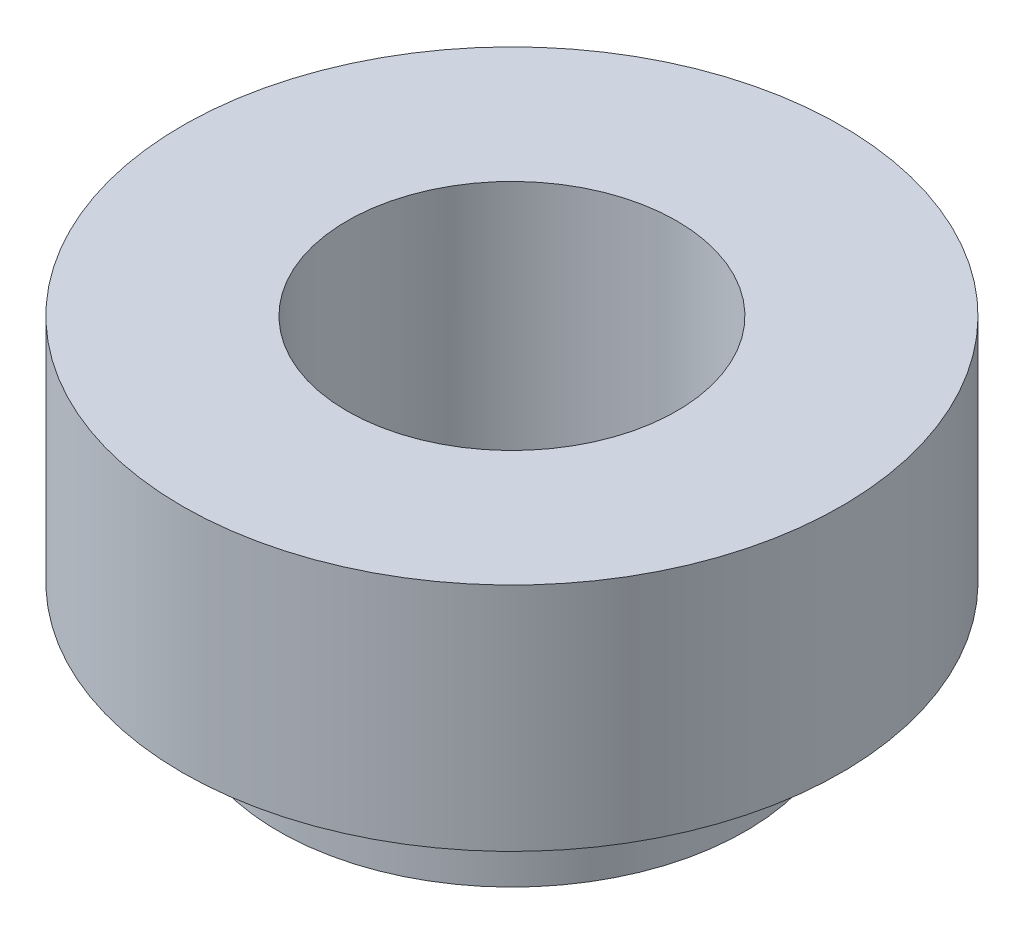
from build123d import *

# Parameters (mm, degrees)
SKETCH_1_R          = 3
EXTRUDE_1_DEPTH     = 2.1
SKETCH_3_R          = 2.125
EXTRUDE_2_DEPTH     = 0.9
SKETCH_4_R          = 1.5
CUT_EXTRUDE_1_DEPTH = 3.3


with BuildPart() as part:
    # ｽｹｯﾁ1 → ﾎﾞｽ - 押し出し1 (new body)
    with BuildSketch(Plane(origin=(0, 0, 0), x_dir=(1, 0, 0), z_dir=(0, 1, 0))):
        Circle(SKETCH_1_R)
    extrude(amount=EXTRUDE_1_DEPTH)

    # ｽｹｯﾁ3 → ﾎﾞｽ - 押し出し2 (add)
    with BuildSketch(Plane(origin=(0, 0, 0), x_dir=(-1, 0, 0), z_dir=(0, -1, 0))):
        Circle(SKETCH_3_R)
    extrude(amount=EXTRUDE_2_DEPTH)

    # ｽｹｯﾁ4 → ｶｯﾄ - 押し出し1 (cut)
    with BuildSketch(Plane(origin=(0, -0.9, 0), x_dir=(-1, 0, 0), z_dir=(0, -1, 0))):
        Circle(SKETCH_4_R)
    extrude(amount=-CUT_EXTRUDE_1_DEPTH, mode=Mode.SUBTRACT)


solid = part.part
